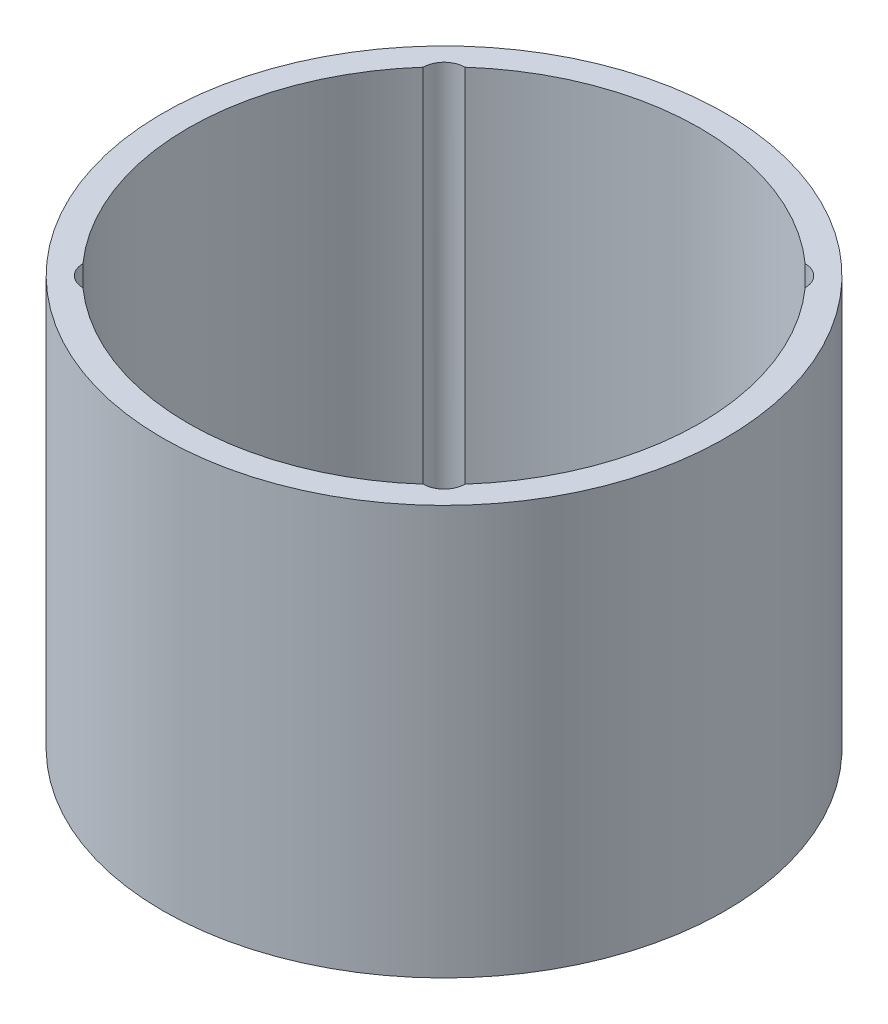
from build123d import *

# Parameters (mm, degrees)
SKETCH1_R           = 55
BOSS_EXTRUDE1_DEPTH = 80
SHELL1_T            = -5
SKETCH2_R           = 4.1
CUT_EXTRUDE1_DEPTH  = 112.579568022


with BuildPart() as part:
    # Sketch1 → Boss-Extrude1 (new body)
    with BuildSketch(Plane(origin=(0, 0, 0), x_dir=(1, 0, 0), z_dir=(0, 1, 0))):
        with Locations(Location((0, 0, 0), (0, 0, 270))):
            Circle(SKETCH1_R)
    extrude(amount=BOSS_EXTRUDE1_DEPTH)

    # Shell1
    shell1_openings = [part.faces().sort_by_distance(p)[0] for p in [
        (0, 80, 0),
    ]]
    offset(amount=SHELL1_T, openings=shell1_openings, kind=Kind.INTERSECTION)

    # Sketch2 → Cut-Extrude1 (cut, through all)
    with BuildSketch(Plane(origin=(0, 80, 0), x_dir=(1, 0, 0), z_dir=(0, 1, 0))):
        with Locations(Location((-33.234018716, -33.234018716, 0), (0, 0, 270))):
            Circle(SKETCH2_R)
        with Locations(Location((-33.234018716, 33.234018716, 0), (0, 0, 270))):
            Circle(SKETCH2_R)
        with Locations(Location((33.234018716, 33.234018716, 0), (0, 0, 270))):
            Circle(SKETCH2_R)
        with Locations(Location((33.234018716, -33.234018716, 0), (0, 0, 270))):
            Circle(SKETCH2_R)
    extrude(amount=-CUT_EXTRUDE1_DEPTH, mode=Mode.SUBTRACT)


solid = part.part
